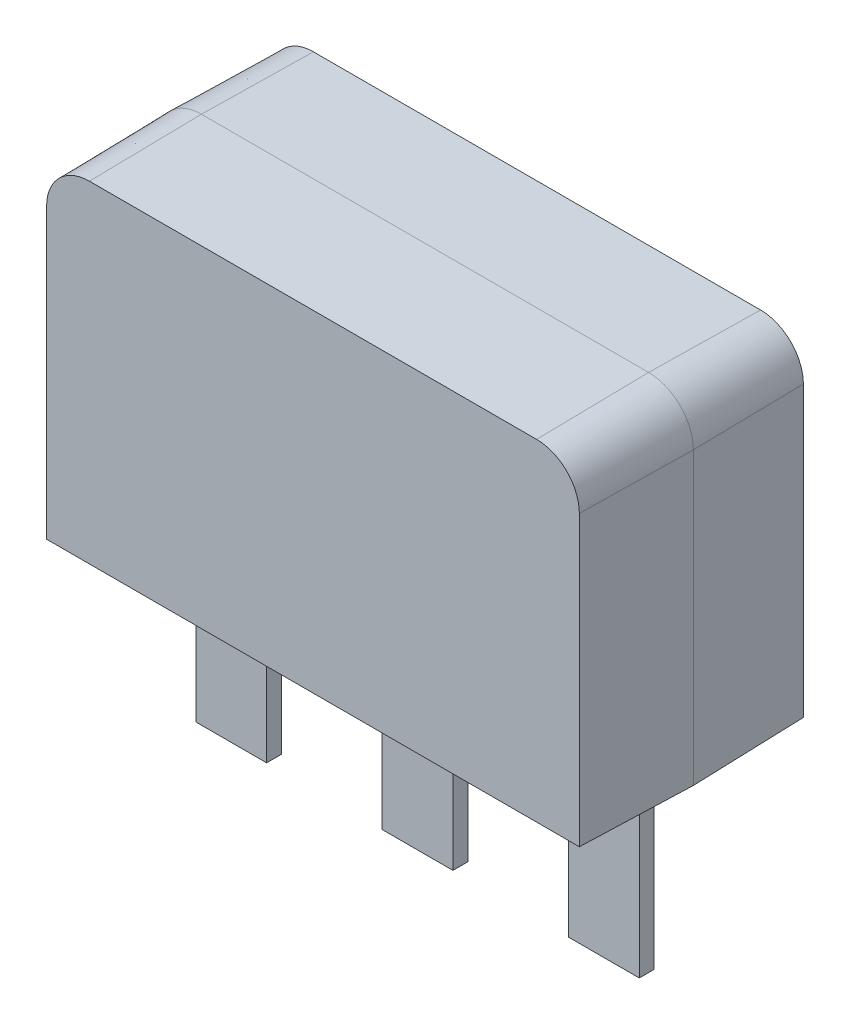
from build123d import *

# Parameters (mm, degrees)
SKETCH3_W                     = 950
SKETCH3_H                     = 200
BOSS_EXTRUDE1_DEPTH           = 2499
BOSS_EXTRUDE1_2_DEPTH         = 2499
BOSS_EXTRUDE1_3_DEPTH         = 2499
BOSS_EXTRUDE3_DEPTH           = 1503
BOSS_EXTRUDE3_TAPER           = 1
BOSS_EXTRUDE3_OTHER_WAY_DEPTH = 1503
BOSS_EXTRUDE3_OTHER_WAY_TAPER = 1


with BuildPart() as part:
    # Sketch3 → Boss-Extrude1 (new body)
    with BuildSketch(Plane(origin=(0, 0, 0), x_dir=(1, 0, 0), z_dir=(0, 1, 0))):
        with Locations((-2500, 0)):
            Rectangle(SKETCH3_W, SKETCH3_H)
    extrude(amount=-BOSS_EXTRUDE1_DEPTH)



with BuildPart() as body_2:
    # Sketch3 → Boss-Extrude1 2 (new body)
    with BuildSketch(Plane(origin=(0, 0, 0), x_dir=(1, 0, 0), z_dir=(0, 1, 0))):
        with Locations((2500, 0)):
            Rectangle(SKETCH3_W, SKETCH3_H)
    extrude(amount=-BOSS_EXTRUDE1_2_DEPTH)


with BuildPart() as body_3:
    # Sketch3 → Boss-Extrude1 3 (new body)
    with BuildSketch(Plane(origin=(0, 0, 0), x_dir=(1, 0, 0), z_dir=(0, 1, 0))):
        Rectangle(SKETCH3_W, SKETCH3_H)
    extrude(amount=-BOSS_EXTRUDE1_3_DEPTH)


with BuildPart() as body_4:
    # Sketch1 → Boss-Extrude3 (new body)
    with BuildSketch(Plane.XY):
        with BuildLine():
            Line((3600, 0), (3600, 3900))
            ThreePointArc((3600, 3900), (3424.264068712, 4324.264068712), (3000, 4500))
            Line((3000, 4500), (-3000, 4500))
            ThreePointArc((-3000, 4500), (-3424.264068712, 4324.264068712), (-3600, 3900))
            Line((-3600, 3900), (-3600, 0))
            Line((-3600, 0), (3600, 0))
        make_face()
    extrude(amount=BOSS_EXTRUDE3_DEPTH, taper=BOSS_EXTRUDE3_TAPER)


with BuildPart() as part_1:
    add(part.part)

    add(body_2.part)  # Boss-Extrude3 other way merges body 2

    add(body_3.part)  # Boss-Extrude3 other way merges body 3

    add(body_4.part)  # Boss-Extrude3 other way merges body 4
    # Sketch1 → Boss-Extrude3 other way (add)
    with BuildSketch(Plane.XY):
        with BuildLine():
            Line((3600, 0), (3600, 3900))
            ThreePointArc((3600, 3900), (3424.264068712, 4324.264068712), (3000, 4500))
            Line((3000, 4500), (-3000, 4500))
            ThreePointArc((-3000, 4500), (-3424.264068712, 4324.264068712), (-3600, 3900))
            Line((-3600, 3900), (-3600, 0))
            Line((-3600, 0), (3600, 0))
        make_face()
    extrude(amount=-BOSS_EXTRUDE3_OTHER_WAY_DEPTH, taper=BOSS_EXTRUDE3_OTHER_WAY_TAPER)


solid = part_1.part
